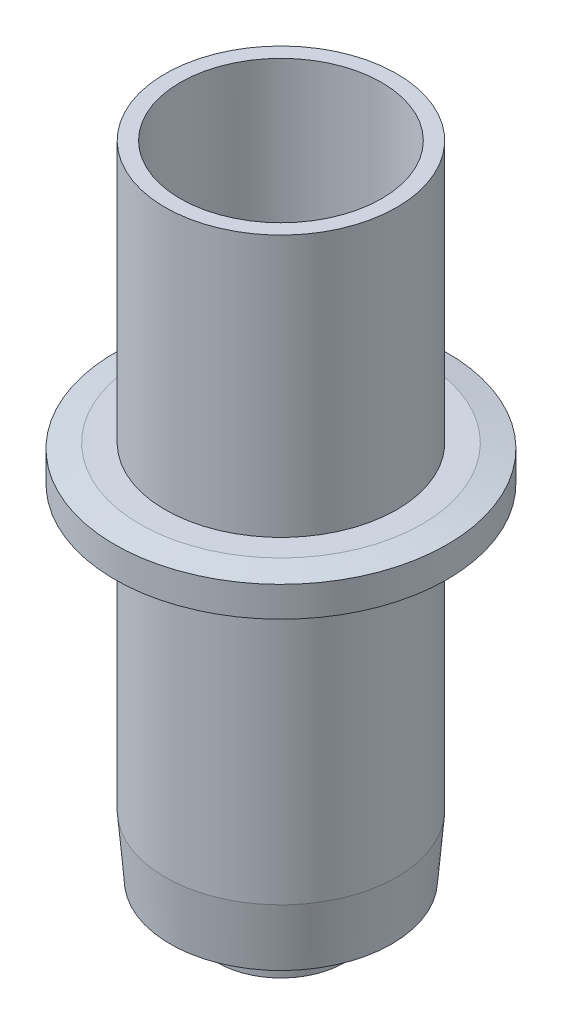
from build123d import *

# Parameters (mm, degrees)
SKETCH3_R          = 4.087752765
CUT_EXTRUDE1_DEPTH = 3.5


with BuildPart() as part:
    # Sketch1 → 5.63 mm bottom to pen tip (revolve)
    with BuildSketch(Plane.XY):
        Polygon((0, 0), (3, 0), (3.2, 5.5), (5.5, 5.5), (5.75, 8.5), (5.75, 22.3), (7, 22.3), (8.25, 22.55), (8.25, 24.05), (7, 24.3), (5.75, 24.3), (5.75, 37.3), (0, 37.3), align=None)
    revolve(axis=Axis((0, -143.950460456, 0), (0, 1, 0)))

    # Sketch2 → Cut-Revolve1 (revolve, cut)
    with BuildSketch(Plane(origin=(0, 0, 0), x_dir=(0, 0, -1), z_dir=(1, 0, 0))):
        Polygon((0.75, -5.63), (0.75, -0.43), (2.575, -0.43), (2.575, 6.87), (5, 6.87), (5, 39.162156903), (0, 39.162156903), (0, -5.63), align=None)
    revolve(axis=Axis((0, -1000, 0), (0, 1, 0)), mode=Mode.SUBTRACT)

    # Sketch3 → Cut-Extrude1 (cut)
    with BuildSketch(Plane(origin=(0, 0, 0), x_dir=(-1, 0, 0), z_dir=(0, -1, 0))):
        Circle(SKETCH3_R)
    extrude(amount=-CUT_EXTRUDE1_DEPTH, mode=Mode.SUBTRACT)


solid = part.part
